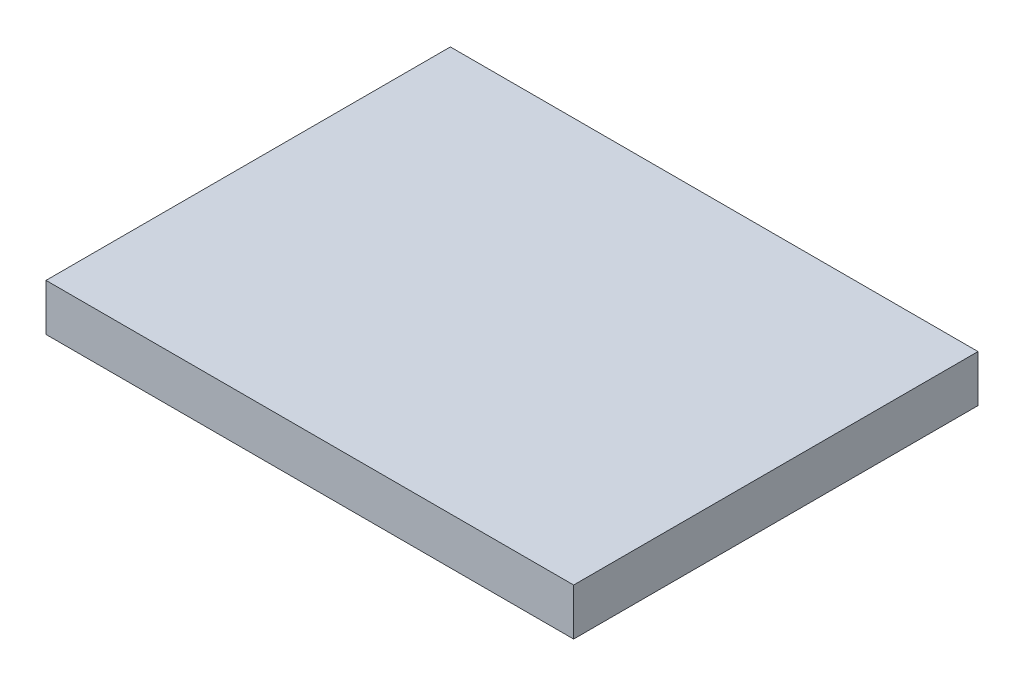
from build123d import *

# Parameters (mm, degrees)
SKETCH_1_W      = 107
SKETCH_1_H      = 82
EXTRUDE_1_DEPTH = 9.5


with BuildPart() as part:
    # ｽｹｯﾁ1 → ﾎﾞｽ - 押し出し1 (new body)
    with BuildSketch(Plane(origin=(0, 0, 0), x_dir=(1, 0, 0), z_dir=(0, 1, 0))):
        Rectangle(SKETCH_1_W, SKETCH_1_H)
    extrude(amount=EXTRUDE_1_DEPTH)


solid = part.part
